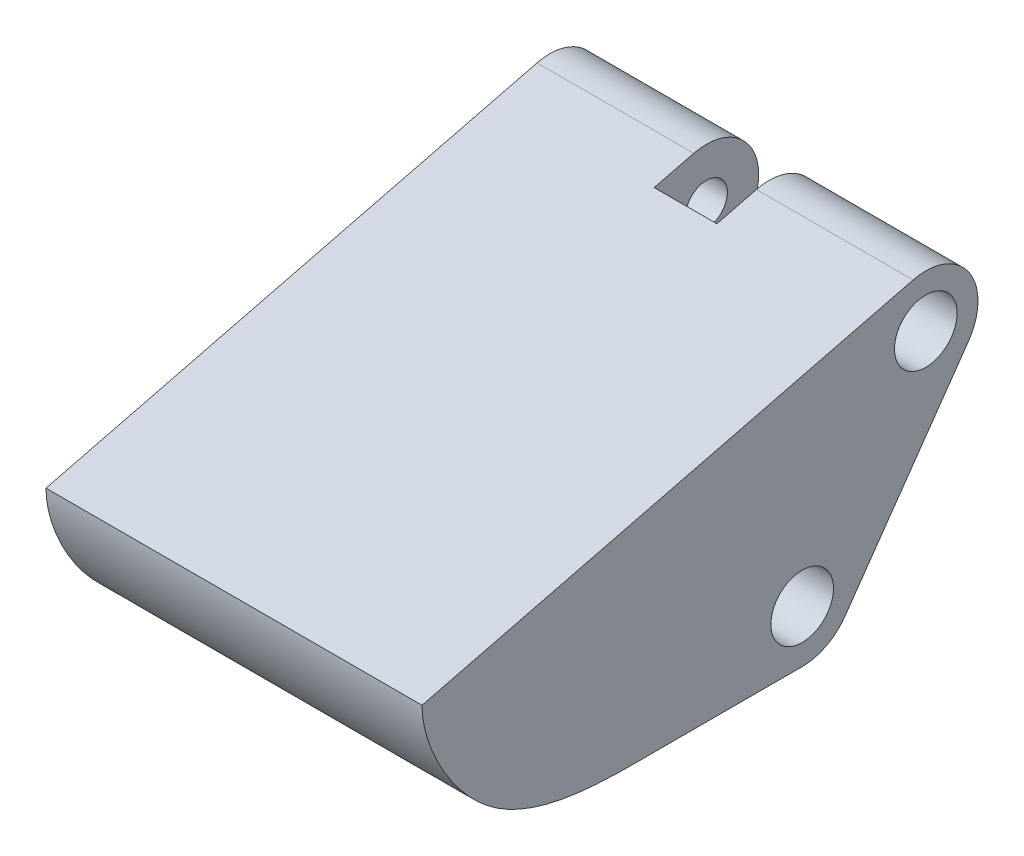
from build123d import *

# Parameters (mm, degrees)
SKETCH2_R           = 1
BOSS_EXTRUDE1_DEPTH = 9
SKETCH4_W           = 3
SKETCH4_H           = 5
CUT_EXTRUDE1_DEPTH  = 15
SKETCH5_W           = 6
SKETCH5_H           = 10
CUT_EXTRUDE3_DEPTH  = 5.25
SKETCH6_R           = 1.5
CUT_EXTRUDE4_DEPTH  = 3
SKETCH7_R           = 1.5
CUT_EXTRUDE5_DEPTH  = 3


with BuildPart() as part:
    # Sketch2 → Boss-Extrude1 (new body, symmetric)
    with BuildSketch(Plane(origin=(0, 0, 0), x_dir=(0, 0, -1), z_dir=(1, 0, 0))):
        with BuildLine():
            Line((-6.491790717, 5.877052321), (-30, 0))
            add(Edge.make_bspline(
                [(-30, 0), (-30, -1.825107758), (-26.893202648, -7.805962947), (-20.772810337, -7.5), (-18.5, -7.5)],
                knots=[0, 0, 0, 0, 0.460452824, 1, 1, 1, 1], degree=3))
            Line((-18.5, -7.5), (-11.801638904, -7.5))
            ThreePointArc((-11.801638904, -7.5), (-10.647112952, -7.217446691), (-9.753559103, -6.433655861))
            Line((-9.753559103, -6.433655861), (-3.837371853, 2.018040209))
            ThreePointArc((-3.837371853, 2.018040209), (-3.825682806, 4.868506676), (-6.491790717, 5.877052321))
        make_face()
        with Locations((-11.801638904, -5)):
            Circle(SKETCH2_R, mode=Mode.SUBTRACT)
        with Locations((-5.885451655, 3.45169607)):
            Circle(SKETCH2_R, mode=Mode.SUBTRACT)
    extrude(amount=BOSS_EXTRUDE1_DEPTH, both=True)

    # Sketch4 → Cut-Extrude1 (cut)
    with BuildSketch(Plane(origin=(0, 5.95169607, 0), x_dir=(1, 0, 0), z_dir=(0, 1, 0))):
        with Locations((0, -5.885451655)):
            Rectangle(SKETCH4_W, SKETCH4_H)
    extrude(amount=-CUT_EXTRUDE1_DEPTH, mode=Mode.SUBTRACT)

    # Sketch5 → Cut-Extrude3 (cut)
    with BuildSketch(Plane.XZ.offset(7.5)):
        with Locations((0, 10.801638904)):
            Rectangle(SKETCH5_W, SKETCH5_H)
    extrude(amount=-CUT_EXTRUDE3_DEPTH, mode=Mode.SUBTRACT)

    # Sketch6 → Cut-Extrude4 (cut)
    with BuildSketch(Plane(origin=(9, 0, 0), x_dir=(0, 0, -1), z_dir=(1, 0, 0))):
        with Locations((-5.885451655, 3.45169607)):
            Circle(SKETCH6_R)
        with Locations((-11.801638904, -5)):
            Circle(SKETCH6_R)
    extrude(amount=-CUT_EXTRUDE4_DEPTH, mode=Mode.SUBTRACT)

    # Sketch7 → Cut-Extrude5 (cut)
    with BuildSketch(Plane.ZY.offset(9)):
        with Locations((5.885451655, 3.45169607)):
            Circle(SKETCH7_R)
        with Locations((11.801638904, -5)):
            Circle(SKETCH7_R)
    extrude(amount=-CUT_EXTRUDE5_DEPTH, mode=Mode.SUBTRACT)


solid = part.part
